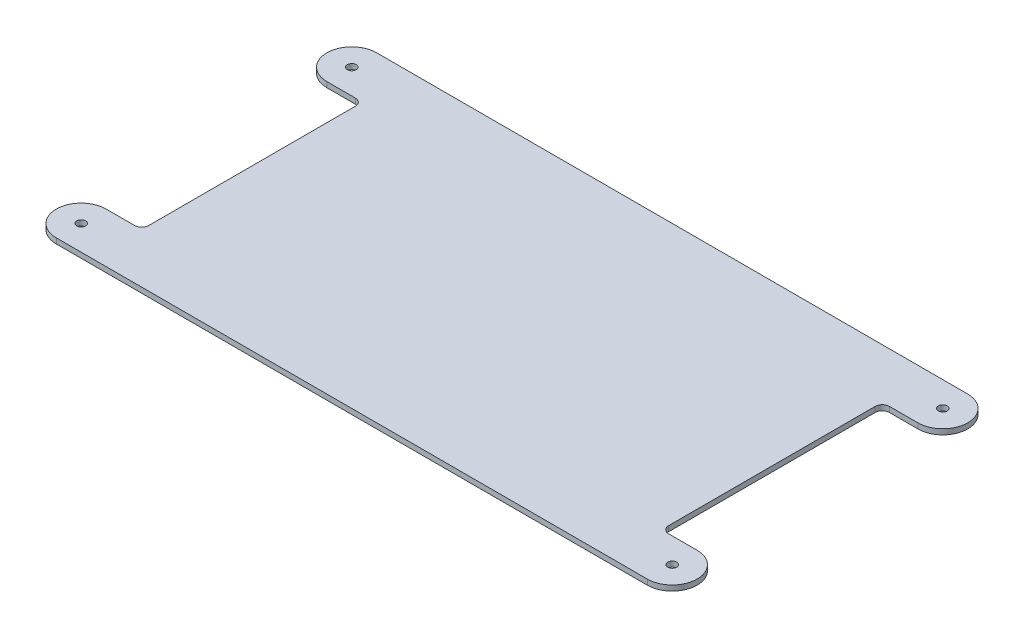
from build123d import *

# Parameters (mm, degrees)
BOSS_EXTRUDE1_DEPTH = 3.81
SKETCH2_R           = 3.175
CUT_EXTRUDE1_DEPTH  = 85.852


with BuildPart() as part:
    # Sketch1 → Boss-Extrude1 (new body)
    with BuildSketch(Plane(origin=(0, 0, 0), x_dir=(1, 0, 0), z_dir=(0, 1, 0))):
        with BuildLine():
            Line((-106.328404832, 71.61361972), (-235.457093287, 71.61361972))
            ThreePointArc((-235.457093287, 71.61361972), (-253.237093287, 53.83361972), (-235.457093287, 36.05361972))
            Line((-235.457093287, 36.05361972), (-215.137093287, 36.05361972))
            ThreePointArc((-215.137093287, 36.05361972), (-211.544990839, 34.565722168), (-210.057093287, 30.97361972))
            Line((-210.057093287, 30.97361972), (-210.057093287, -116.34638028))
            ThreePointArc((-210.057093287, -116.34638028), (-211.544990839, -119.938482729), (-215.137093287, -121.42638028))
            Line((-215.137093287, -121.42638028), (-235.457093287, -121.42638028))
            ThreePointArc((-235.457093287, -121.42638028), (-253.237093287, -139.20638028), (-235.457093287, -156.98638028))
            Line((-235.457093287, -156.98638028), (-106.328404832, -156.98638028))
            Line((-106.328404832, -156.98638028), (160.782906713, -156.98638028))
            Line((160.782906713, -156.98638028), (186.182906713, -156.98638028))
            ThreePointArc((186.182906713, -156.98638028), (203.962906713, -139.20638028), (186.182906713, -121.42638028))
            Line((186.182906713, -121.42638028), (165.862906713, -121.42638028))
            ThreePointArc((165.862906713, -121.42638028), (162.270804264, -119.938482729), (160.782906713, -116.34638028))
            Line((160.782906713, -116.34638028), (160.782906713, 30.97361972))
            ThreePointArc((160.782906713, 30.97361972), (162.270804264, 34.565722168), (165.862906713, 36.05361972))
            Line((165.862906713, 36.05361972), (186.182906713, 36.05361972))
            ThreePointArc((186.182906713, 36.05361972), (203.962906713, 53.83361972), (186.182906713, 71.61361972))
            Line((186.182906713, 71.61361972), (160.782906713, 71.61361972))
            Line((160.782906713, 71.61361972), (-106.328404832, 71.61361972))
        make_face()
    extrude(amount=BOSS_EXTRUDE1_DEPTH)

    # Sketch2 → Cut-Extrude1 (cut)
    with BuildSketch(Plane(origin=(0, 3.81, 0), x_dir=(1, 0, 0), z_dir=(0, 1, 0))):
        with Locations((-235.457093287, 53.83361972)):
            Circle(SKETCH2_R)
        with Locations((186.182906713, 53.83361972)):
            Circle(SKETCH2_R)
        with Locations((186.182906713, -139.20638028)):
            Circle(SKETCH2_R)
        with Locations((-235.457093287, -139.20638028)):
            Circle(SKETCH2_R)
    extrude(amount=-CUT_EXTRUDE1_DEPTH, mode=Mode.SUBTRACT)


solid = part.part
